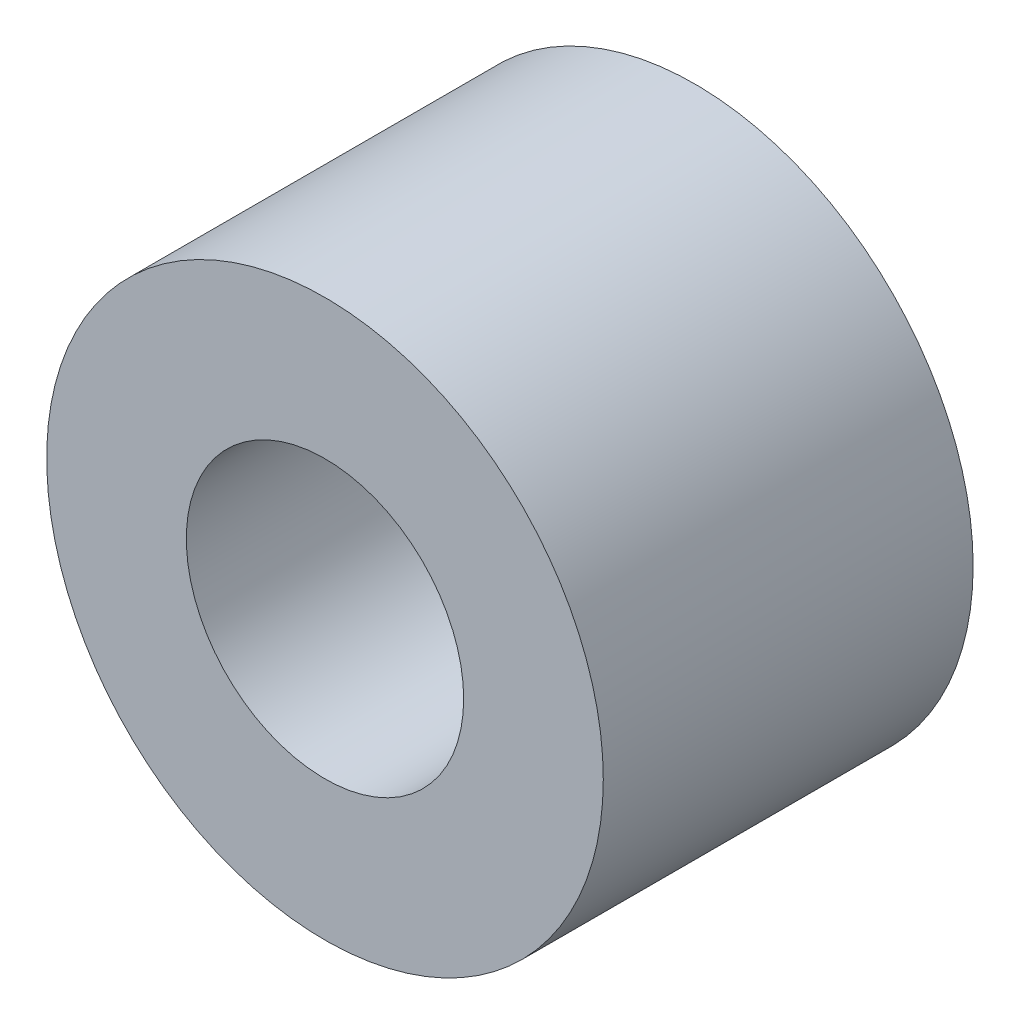
from build123d import *

# Parameters (mm, degrees)
SKETCH1_R           = 3.01
SKETCH1_R_2         = 1.5
BOSS_EXTRUDE1_DEPTH = 2


with BuildPart() as part:
    # Sketch1 → Boss-Extrude1 (new, symmetric)
    with BuildSketch(Plane.XY):
        Circle(SKETCH1_R)
        Circle(SKETCH1_R_2, mode=Mode.SUBTRACT)
    extrude(amount=BOSS_EXTRUDE1_DEPTH, both=True)


solid = part.part
